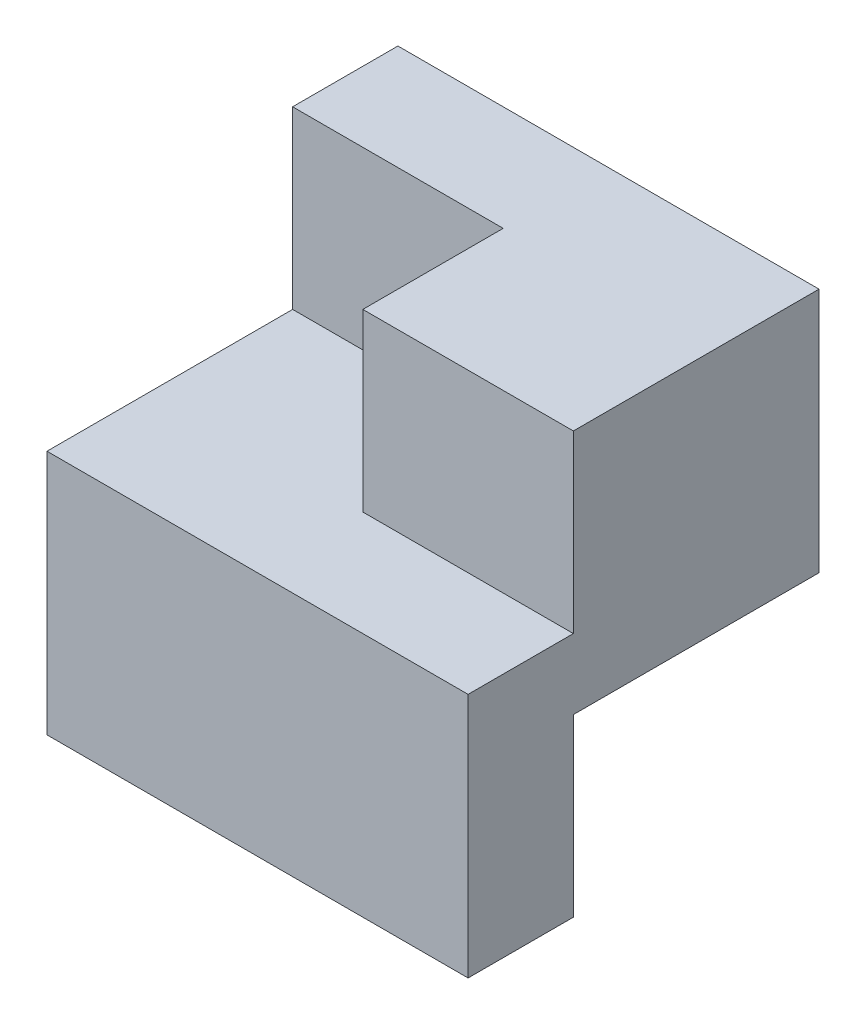
from build123d import *

# Parameters (mm, degrees)
SKETCH1_W           = 6
SKETCH1_H           = 5
BOSS_EXTRUDE1_DEPTH = 6
CUT_EXTRUDE1_DEPTH  = 2.5
CUT_EXTRUDE2_DEPTH  = 2.5


with BuildPart() as part:
    # Sketch1 → Boss-Extrude1 (new body)
    with BuildSketch(Plane(origin=(0, 0, 0), x_dir=(1, 0, 0), z_dir=(0, 1, 0))):
        Rectangle(SKETCH1_W, SKETCH1_H)
    extrude(amount=BOSS_EXTRUDE1_DEPTH)

    # Sketch2 → Cut-Extrude1 (cut)
    with BuildSketch(Plane(origin=(0, 6, 0), x_dir=(1, 0, 0), z_dir=(0, 1, 0))):
        Polygon((3, -1), (0, -1), (0, 1), (-3, 1), (-3, -2.5), (3, -2.5), align=None)
    extrude(amount=-CUT_EXTRUDE1_DEPTH, mode=Mode.SUBTRACT)

    # Sketch3 → Cut-Extrude2 (cut)
    with BuildSketch(Plane.XZ):
        Polygon((3, -2.5), (3, 1), (0, 1), (0, -1), (-3, -1), (-3, -2.5), align=None)
    extrude(amount=-CUT_EXTRUDE2_DEPTH, mode=Mode.SUBTRACT)


solid = part.part
